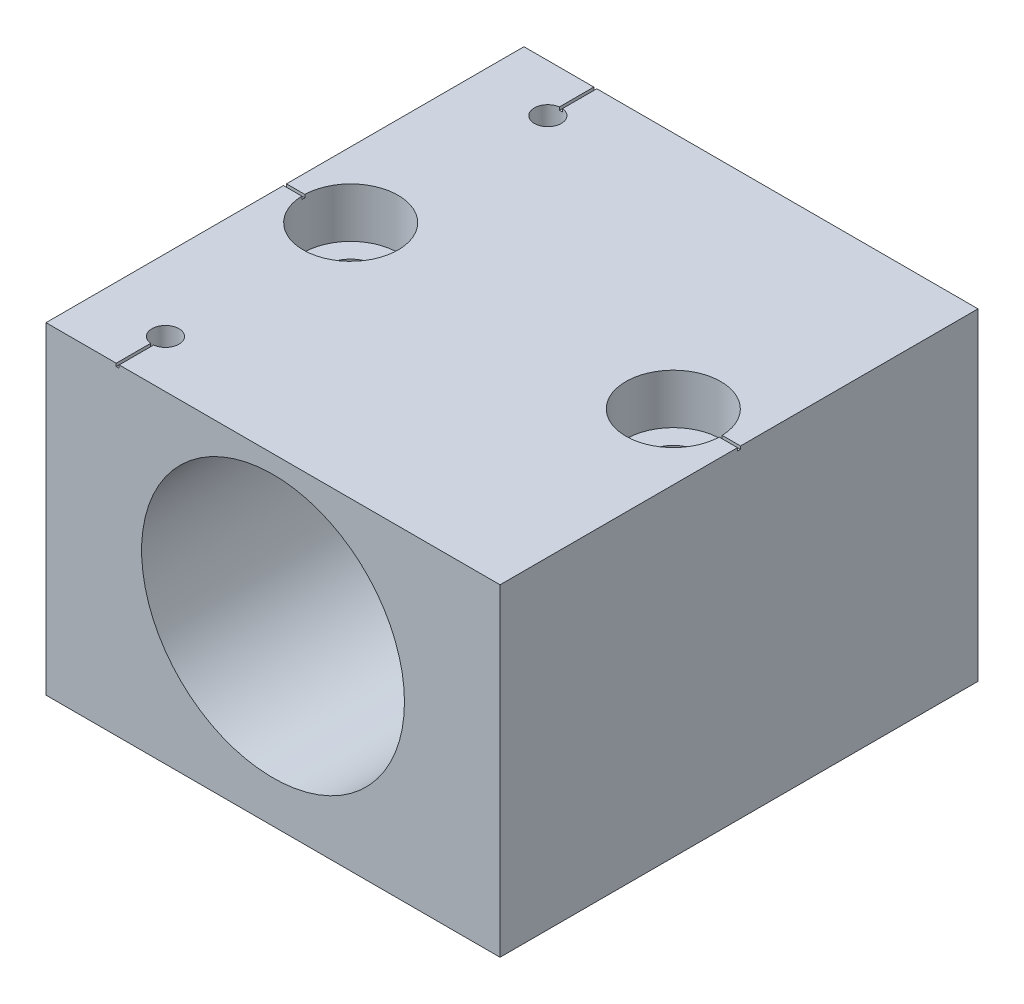
from build123d import *

# Parameters (mm, degrees)
SKETCH1_W                                      = 38
SKETCH1_H                                      = 27
EXTRUDE1_DEPTH                                 = 20
SKETCH2_R                                      = 11
LIGHT_WEIGHTING_HOLE_DEPTH                     = 21
LIGHT_WEIGHTING_HOLE_DEPTH_BACK                = 21
F_4_40_TAPPED_HOLE1_D                          = 2.2606
F_4_40_TAPPED_HOLE1_DEPTH                      = 8.8646
F_4_40_TAPPED_HOLE1_TIP                        = 0.679152758
CBORE_FOR_8_SOCKET_HEAD_CAP_SCREW1_D           = 4.3053
CBORE_FOR_8_SOCKET_HEAD_CAP_SCREW1_CBORE_D     = 7.9375
CBORE_FOR_8_SOCKET_HEAD_CAP_SCREW1_CBORE_DEPTH = 4.1656
SKETCH9_W                                      = 0.25
SKETCH9_H                                      = 4
SKETCH9_W_2                                    = 2.002359623
SKETCH9_H_2                                    = 0.25
SKETCH9_W_3                                    = 2.12486514
CUT_EXTRUDE1_DEPTH                             = 0.25


with BuildPart() as part:
    # Sketch1 → Extrude1 (new body, symmetric)
    with BuildSketch(Plane.XY):
        with Locations((0, 13.5)):
            Rectangle(SKETCH1_W, SKETCH1_H)
    extrude(amount=EXTRUDE1_DEPTH, both=True)

    # Sketch2 → Light-Weighting Hole (cut, two sides)
    with BuildSketch(Plane.XY) as light_weighting_hole_sk:
        with Locations((0, 14.5)):
            Circle(SKETCH2_R)
    extrude(amount=LIGHT_WEIGHTING_HOLE_DEPTH, mode=Mode.SUBTRACT)
    extrude(light_weighting_hole_sk.sketch, amount=-LIGHT_WEIGHTING_HOLE_DEPTH_BACK, mode=Mode.SUBTRACT)

    # #4-40 Tapped Hole1
    with Locations(Plane(origin=(0, 27, 0), x_dir=(-1, 0, 0), z_dir=(0, 1, 0))):
        with Locations((13, -16), (13, 16)):
            Hole(F_4_40_TAPPED_HOLE1_D / 2, depth=F_4_40_TAPPED_HOLE1_DEPTH)
            with Locations((0, 0, -(F_4_40_TAPPED_HOLE1_DEPTH + F_4_40_TAPPED_HOLE1_TIP / 2))):  # 118° drill point
                Cone(0, F_4_40_TAPPED_HOLE1_D / 2, F_4_40_TAPPED_HOLE1_TIP, mode=Mode.SUBTRACT)

    # CBORE for #8 Socket Head Cap Screw1 (through all)
    with Locations(Plane(origin=(0, 27, 0), x_dir=(-1, 0, 0), z_dir=(0, 1, 0))):
        with Locations((13.5, 0), (-13.5, 0)):
            CounterBoreHole(CBORE_FOR_8_SOCKET_HEAD_CAP_SCREW1_D / 2, CBORE_FOR_8_SOCKET_HEAD_CAP_SCREW1_CBORE_D / 2, CBORE_FOR_8_SOCKET_HEAD_CAP_SCREW1_CBORE_DEPTH)

    # Sketch9 → Cut-Extrude1 (cut)
    with BuildSketch(Plane(origin=(0, 27, 0), x_dir=(-1, 0, 0), z_dir=(0, 1, 0))):
        with Locations((13.026450264, -18)):
            Rectangle(SKETCH9_W, SKETCH9_H)
        with Locations((12.998090527, 18)):
            Rectangle(SKETCH9_W, SKETCH9_H)
        with Locations((-17.998820188, 0)):
            Rectangle(SKETCH9_W_2, SKETCH9_H_2)
        with Locations((17.93756743, 0)):
            Rectangle(SKETCH9_W_3, SKETCH9_H_2)
    extrude(amount=-CUT_EXTRUDE1_DEPTH, mode=Mode.SUBTRACT)


solid = part.part
